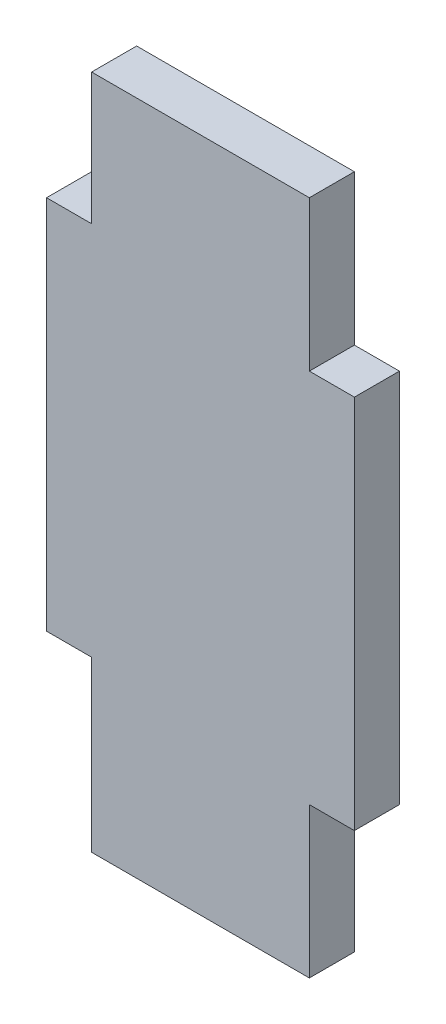
from build123d import *

# Parameters (mm, degrees)
RESSALTO_EXTRUS_O1_DEPTH = 3
ESBO_O2_W                = 3
ESBO_O2_H                = 10
CORTE_EXTRUS_O1_DEPTH    = 3


with BuildPart() as part:
    # Esboço1 → Ressalto-extrusão1 (new body)
    with BuildSketch(Plane.XY):
        Polygon((-47.770728993, -6.458333333), (-47.770728993, -17.708333333), (-30.270728993, -17.708333333), (-30.270728993, 27.291666667), (-47.770728993, 27.291666667), (-47.770728993, 18.541666667), (-50.770728993, 18.541666667), (-50.770728993, -6.458333333), align=None)
    extrude(amount=RESSALTO_EXTRUS_O1_DEPTH)

    # Esboço2 → Corte-extrusão1 (cut)
    with BuildSketch(Plane.XY.offset(3)):
        with Locations((-31.770728993, 22.291666667)):
            Rectangle(ESBO_O2_W, ESBO_O2_H)
        with Locations((-31.770728993, -12.708333333)):
            Rectangle(ESBO_O2_W, ESBO_O2_H)
    extrude(amount=-CORTE_EXTRUS_O1_DEPTH, mode=Mode.SUBTRACT)


solid = part.part
